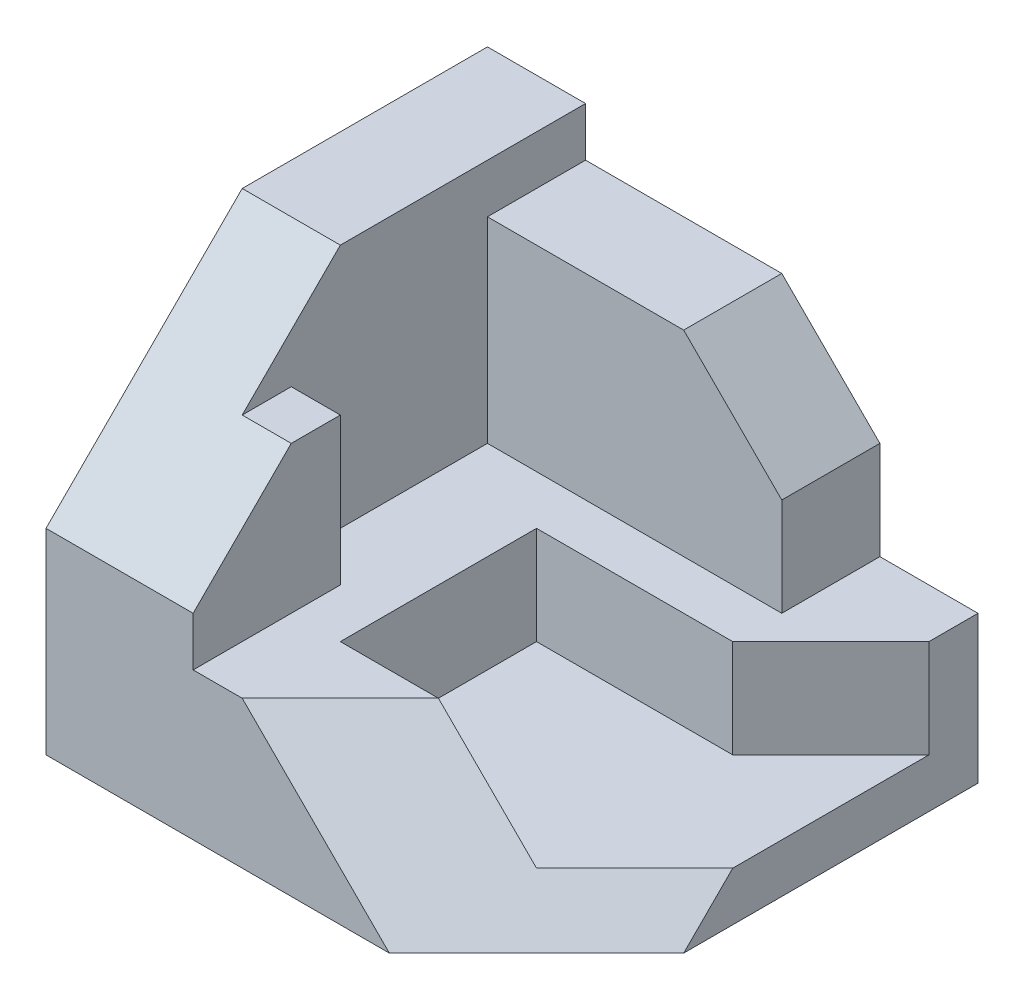
from build123d import *

# Parameters (mm, degrees)
SKETCH3_W           = 100
SKETCH3_H           = 80
BOSS_EXTRUDE1_DEPTH = 90
CUT_EXTRUDE1_DEPTH  = 90
CUT_EXTRUDE2_DEPTH  = 90
CUT_EXTRUDE3_DEPTH  = 90
SKETCH8_W           = 40
SKETCH8_H           = 60
CUT_EXTRUDE4_DEPTH  = 60
SKETCH9_W           = 30
SKETCH9_H           = 30
CUT_EXTRUDE5_DEPTH  = 60
SKETCH10_W          = 10
SKETCH10_H          = 10
CUT_EXTRUDE6_DEPTH  = 60
SKETCH11_W          = 40
SKETCH11_H          = 60
BOSS_EXTRUDE2_DEPTH = 20
SKETCH12_W          = 40
SKETCH12_H          = 20
BOSS_EXTRUDE3_DEPTH = 40
SKETCH13_W          = 30
SKETCH13_H          = 10
CUT_EXTRUDE7_DEPTH  = 40
CUT_EXTRUDE8_DEPTH  = 40
CUT_EXTRUDE9_DEPTH  = 20
SKETCH17_W          = 20
SKETCH17_H          = 20
CUT_EXTRUDE10_DEPTH = 84
CUT_EXTRUDE12_DEPTH = 20
CUT_EXTRUDE15_DEPTH = 10
CUT_EXTRUDE17_DEPTH = 77
CUT_EXTRUDE19_DEPTH = 77
CUT_EXTRUDE20_DEPTH = 77
CUT_EXTRUDE21_DEPTH = 77


with BuildPart() as part:
    # Sketch3 → Boss-Extrude1 (new body)
    with BuildSketch(Plane.XY):
        with Locations((50, 40)):
            Rectangle(SKETCH3_W, SKETCH3_H)
    extrude(amount=-BOSS_EXTRUDE1_DEPTH)

    # Sketch4 → Cut-Extrude1 (cut)
    with BuildSketch(Plane.XY):
        Polygon((20, 80), (20, 70), (60, 70), (80, 50), (80, 30), (100, 30), (100, 80), align=None)
    extrude(amount=-CUT_EXTRUDE1_DEPTH, mode=Mode.SUBTRACT)

    # Sketch5 → Cut-Extrude2 (cut)
    with BuildSketch(Plane(origin=(0, 0, 0), x_dir=(-1, 0, 0), z_dir=(0, -1, 0))):
        Polygon((-70, 0), (-100, 30), (-100, 0), align=None)
    extrude(amount=-CUT_EXTRUDE2_DEPTH, mode=Mode.SUBTRACT)

    # Sketch7 → Cut-Extrude3 (cut)
    with BuildSketch(Plane.ZY):
        Polygon((-40, 80), (0, 40), (0, 80), align=None)
    extrude(amount=-CUT_EXTRUDE3_DEPTH, mode=Mode.SUBTRACT)

    # Sketch8 → Cut-Extrude4 (cut)
    with BuildSketch(Plane(origin=(0, 70, 0), x_dir=(1, 0, 0), z_dir=(0, 1, 0))):
        with Locations((40, 60)):
            Rectangle(SKETCH8_W, SKETCH8_H)
    extrude(amount=-CUT_EXTRUDE4_DEPTH, mode=Mode.SUBTRACT)

    # Sketch9 → Cut-Extrude5 (cut)
    with BuildSketch(Plane(origin=(0, 0, -30), x_dir=(-1, 0, 0), z_dir=(0, 0, -1))):
        with Locations((-45, 55)):
            Rectangle(SKETCH9_W, SKETCH9_H)
    extrude(amount=-CUT_EXTRUDE5_DEPTH, mode=Mode.SUBTRACT)

    # Sketch10 → Cut-Extrude6 (cut)
    with BuildSketch(Plane(origin=(0, 0, -30), x_dir=(-1, 0, 0), z_dir=(0, 0, -1))):
        with Locations((-25, 65)):
            Rectangle(SKETCH10_W, SKETCH10_H)
    extrude(amount=-CUT_EXTRUDE6_DEPTH, mode=Mode.SUBTRACT)

    # Sketch11 → Boss-Extrude2 (add)
    with BuildSketch(Plane(origin=(0, 10, 0), x_dir=(1, 0, 0), z_dir=(0, 1, 0))):
        with Locations((40, 60)):
            Rectangle(SKETCH11_W, SKETCH11_H)
    extrude(amount=BOSS_EXTRUDE2_DEPTH)

    # Sketch12 → Boss-Extrude3 (add)
    with BuildSketch(Plane(origin=(0, 30, 0), x_dir=(1, 0, 0), z_dir=(0, 1, 0))):
        with Locations((40, 80)):
            Rectangle(SKETCH12_W, SKETCH12_H)
    extrude(amount=BOSS_EXTRUDE3_DEPTH)

    # Sketch13 → Cut-Extrude7 (cut)
    with BuildSketch(Plane(origin=(0, 0, -30), x_dir=(-1, 0, 0), z_dir=(0, 0, -1))):
        with Locations((-45, 35)):
            Rectangle(SKETCH13_W, SKETCH13_H)
    extrude(amount=-CUT_EXTRUDE7_DEPTH, mode=Mode.SUBTRACT)

    # Sketch15 → Cut-Extrude8 (cut)
    with BuildSketch(Plane.ZY.offset(-60)):
        Polygon((-70, 70), (-70, 30), (0, 30), (0, 40), (-30, 70), align=None)
    extrude(amount=-CUT_EXTRUDE8_DEPTH, mode=Mode.SUBTRACT)

    # Sketch16 → Cut-Extrude9 (cut)
    with BuildSketch(Plane(origin=(0, 30, 0), x_dir=(1, 0, 0), z_dir=(0, 1, 0))):
        Polygon((100, 80), (80, 60), (40, 60), (40, 20), (80, 20), (100, 40), align=None)
    extrude(amount=-CUT_EXTRUDE9_DEPTH, mode=Mode.SUBTRACT)

    # Sketch17 → Cut-Extrude10 (cut)
    with BuildSketch(Plane.XY.offset(-50)):
        with Locations((90, 20)):
            Rectangle(SKETCH17_W, SKETCH17_H)
    extrude(amount=CUT_EXTRUDE10_DEPTH, mode=Mode.SUBTRACT)

    # Sketch19 → Cut-Extrude12 (cut)
    with BuildSketch(Plane.XY.offset(-10)):
        Polygon((80, 10), (60, 30), (80, 30), align=None)
    extrude(amount=CUT_EXTRUDE12_DEPTH, mode=Mode.SUBTRACT)

    # Sketch22 → Cut-Extrude15 (cut)
    with BuildSketch(Plane.XY.offset(-10)):
        Polygon((60, 30), (80, 30), (80, 10), align=None)
    extrude(amount=-CUT_EXTRUDE15_DEPTH, mode=Mode.SUBTRACT)

    # Sketch24 → Cut-Extrude17 (cut)
    with BuildSketch(Plane(origin=(23.333333333, 23.333333333, 23.333333333), x_dir=(0.40824829, 0.40824829, -0.816496581), z_dir=(0.577350269, 0.577350269, 0.577350269))):
        Polygon((53.07227776, -21.213203436), (28.577380332, -7.071067812), (28.577380332, -49.497474683), (53.07227776, -49.497474683), align=None)
    extrude(amount=CUT_EXTRUDE17_DEPTH, mode=Mode.SUBTRACT)

    # Sketch26 → Cut-Extrude19 (cut)
    with BuildSketch(Plane(origin=(35, -35, 0), x_dir=(0, 0, 1), z_dir=(-0.707106781, 0.707106781, 0))):
        Polygon((-20, 63.639610307), (-10, 63.639610307), (0, 49.497474683), align=None)
    extrude(amount=-CUT_EXTRUDE19_DEPTH, mode=Mode.SUBTRACT)

    # Sketch27 → Cut-Extrude20 (cut)
    with BuildSketch(Plane(origin=(45, 45, 0), x_dir=(0, 0, 1), z_dir=(-0.707106781, -0.707106781, 0))):
        Polygon((-20, -49.497474683), (-10, -49.497474683), (-20, -63.639610307), align=None)
    extrude(amount=-CUT_EXTRUDE20_DEPTH, mode=Mode.SUBTRACT)

    # Sketch30 → Cut-Extrude21 (cut)
    with BuildSketch(Plane(origin=(23.333333333, 23.333333333, 23.333333333), x_dir=(-0.816496581, 0.40824829, 0.40824829), z_dir=(-0.577350269, -0.577350269, -0.577350269))):
        Polygon((-69.402209379, 21.213203436), (-93.897106807, 35.355339059), (-93.897106807, 21.213203436), (-81.649658093, 14.142135624), align=None)
    extrude(amount=-CUT_EXTRUDE21_DEPTH, mode=Mode.SUBTRACT)


solid = part.part
